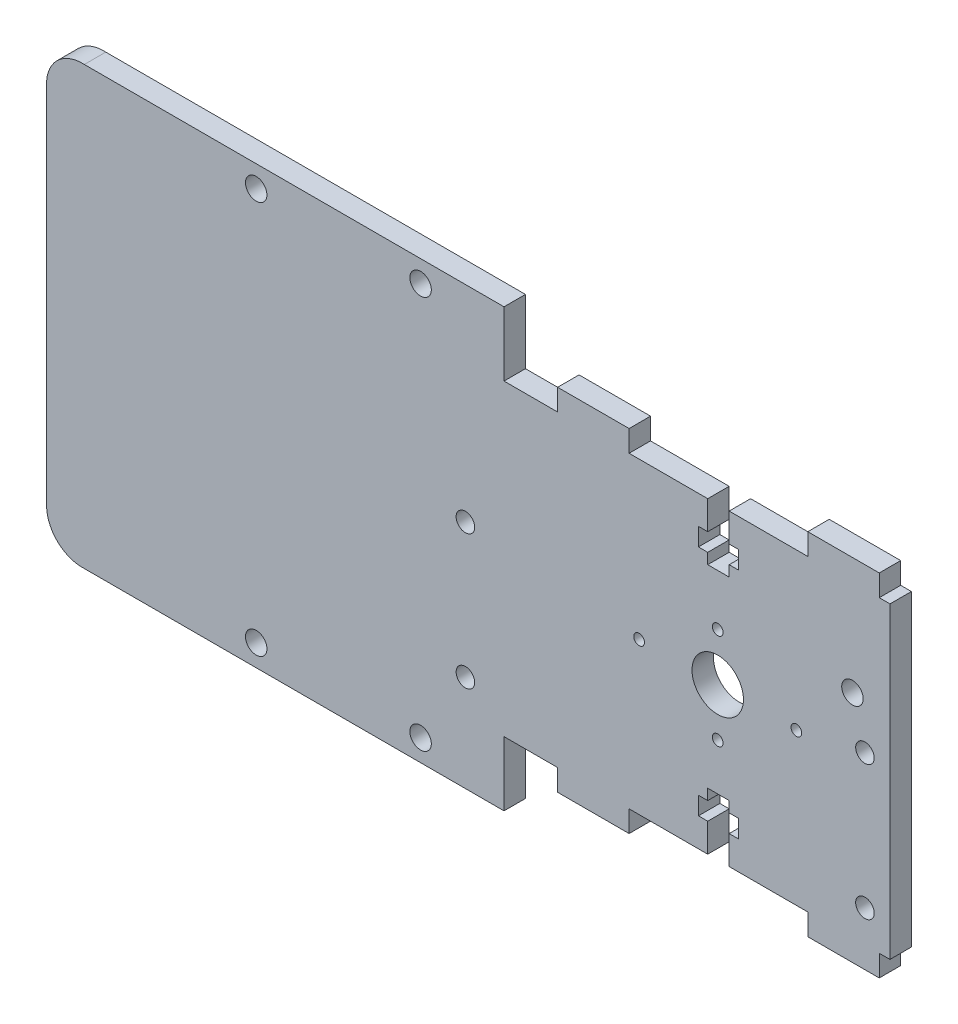
from build123d import *

# Parameters (mm, degrees)
MODEL_R             = 3.6
MODEL_R_2           = 0.75
MODEL_R_3           = 1.500000002
MODEL_R_4           = 1.3
MODEL_R_5           = 1.5
BOSS_EXTRUDE1_DEPTH = 3


with BuildPart() as part:
    # Model → Boss-Extrude1 (new body)
    with BuildSketch(Plane.XY):
        with BuildLine():
            Line((43.808, 64.448), (43.808, 61.448))
            Line((43.808, 61.448), (36.308, 61.448))
            Line((36.308, 61.448), (36.308, 70.448))
            Line((36.308, 70.448), (-22.414233443, 70.448))
            ThreePointArc((-22.414233443, 70.448), (-26.027950405, 69.188749962), (-27.692809934, 65.743041952))
            Line((-27.692809934, 65.743041952), (-27.692809934, 14.360233482))
            ThreePointArc((-27.692809934, 14.360233482), (-26.128440702, 10.72754285), (-22.414233443, 9.368))
            Line((-22.414233443, 9.368), (36.308, 9.368))
            Line((36.308, 9.368), (36.308, 18.368))
            Line((36.308, 18.368), (43.808, 18.368))
            Line((43.808, 18.368), (43.808, 15.368))
            Line((43.808, 15.368), (53.808, 15.368))
            Line((53.808, 15.368), (53.808, 18.368))
            Line((53.808, 18.368), (64.808, 18.368))
            Line((64.808, 18.368), (64.808, 22.368))
            Line((64.808, 22.368), (63.508, 22.368))
            Line((63.508, 22.368), (63.508, 24.868))
            Line((63.508, 24.868), (64.808, 24.868))
            Line((64.808, 24.868), (64.808, 26.368))
            Line((64.808, 26.368), (67.808, 26.368))
            Line((67.808, 26.368), (67.808, 24.868))
            Line((67.808, 24.868), (69.108, 24.868))
            Line((69.108, 24.868), (69.108, 22.368))
            Line((69.108, 22.368), (67.808, 22.368))
            Line((67.808, 22.368), (67.808, 18.368))
            Line((67.808, 18.368), (78.808, 18.368))
            Line((78.808, 18.368), (78.808, 15.368))
            Line((78.808, 15.368), (88.808, 15.368))
            Line((88.808, 15.368), (88.808, 18.368))
            Line((88.808, 18.368), (90.308, 18.368))
            Line((90.308, 18.368), (90.308, 61.448))
            Line((90.308, 61.448), (88.808, 61.448))
            Line((88.808, 61.448), (88.808, 64.448))
            Line((88.808, 64.448), (78.808, 64.448))
            Line((78.808, 64.448), (78.808, 61.448))
            Line((78.808, 61.448), (67.808, 61.448))
            Line((67.808, 61.448), (67.808, 57.4481))
            Line((67.808, 57.4481), (69.108, 57.4481))
            Line((69.108, 57.4481), (69.108, 54.9481))
            Line((69.108, 54.9481), (67.808, 54.9481))
            Line((67.808, 54.9481), (67.808, 53.448))
            Line((67.808, 53.448), (64.808, 53.448))
            Line((64.808, 53.448), (64.808, 54.9481))
            Line((64.808, 54.9481), (63.508, 54.9481))
            Line((63.508, 54.9481), (63.508, 57.4481))
            Line((63.508, 57.4481), (64.808, 57.4481))
            Line((64.808, 57.4481), (64.808, 61.448))
            Line((64.808, 61.448), (53.808, 61.448))
            Line((53.808, 61.448), (53.808, 64.448))
            Line((53.808, 64.448), (43.808, 64.448))
        make_face()
        with Locations((66.20800481, 39.598049108)):
            Circle(MODEL_R, mode=Mode.SUBTRACT)
        with Locations((55.207943868, 39.587694441)):
            Circle(MODEL_R_2, mode=Mode.SUBTRACT)
        with Locations((66.20800481, 46.298)):
            Circle(MODEL_R_2, mode=Mode.SUBTRACT)
        with Locations((66.20800481, 32.898)):
            Circle(MODEL_R_2, mode=Mode.SUBTRACT)
        with Locations((77.20800481, 39.598049108)):
            Circle(MODEL_R_2, mode=Mode.SUBTRACT)
        with Locations((85.058, 48.068)):
            Circle(MODEL_R_3, mode=Mode.SUBTRACT)
        with Locations((30.908, 41.668)):
            Circle(MODEL_R_4, mode=Mode.SUBTRACT)
        with Locations((86.808, 41.668)):
            Circle(MODEL_R_4, mode=Mode.SUBTRACT)
        with Locations((30.908, 22.868)):
            Circle(MODEL_R_4, mode=Mode.SUBTRACT)
        with Locations((86.808, 22.868)):
            Circle(MODEL_R_4, mode=Mode.SUBTRACT)
        with Locations((1.635766557, 67.408)):
            Circle(MODEL_R_5, mode=Mode.SUBTRACT)
        with Locations((24.635766557, 67.408)):
            Circle(MODEL_R_5, mode=Mode.SUBTRACT)
        with Locations((1.635766557, 12.408)):
            Circle(MODEL_R_5, mode=Mode.SUBTRACT)
        with Locations((24.635766557, 12.408)):
            Circle(MODEL_R_5, mode=Mode.SUBTRACT)
    extrude(amount=BOSS_EXTRUDE1_DEPTH)


solid = part.part
